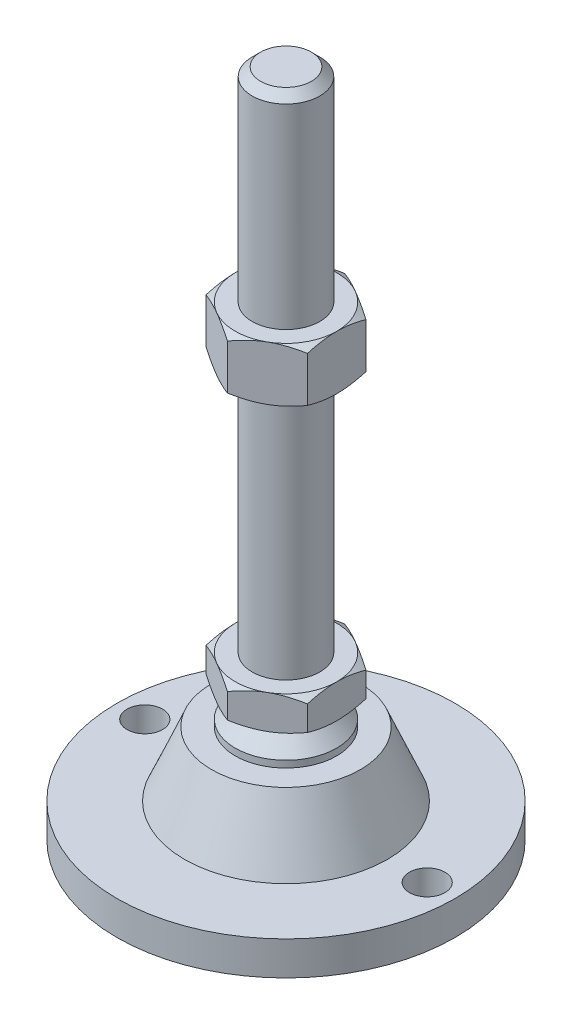
from build123d import *

# Parameters (mm, degrees)
EXTRUDE_1_DEPTH     = 10
EXTRUDE_2_DEPTH     = 16
SKETCH_5_R          = 5.25
CUT_EXTRUDE_1_DEPTH = 11


with BuildPart() as part:
    # Эскиз1 → Повернуть1 (revolve)
    with BuildSketch(Plane.XY, mode=Mode.PRIVATE) as revolve_1_sk:
        Polygon((0, 0), (-50, 0), (-50, 10), (-30, 10), (-22, 29), (-15, 29), (-15, 31), (-10, 36), (-10, 38), (-10, 48), (-10, 195.5), (-7.5, 198), (0, 198), align=None)
    revolve(revolve_1_sk.sketch.rotate(Axis((0, 0, 0), (0, 1, 0)), 180), axis=Axis((0, 0, 0), (0, 1, 0)))  # turned: the seam where the file's is

    # Эскиз2 → Бобышка-Вытянуть1 (add)
    with BuildSketch(Plane(origin=(0, 38, 0), x_dir=(1, 0, 0), z_dir=(0, 1, 0))):
        Polygon((0, 17.320508076), (-15, 8.660254038), (-15, -8.660254038), (0, -17.320508076), (15, -8.660254038), (15, 8.660254038), align=None)
    extrude(amount=EXTRUDE_1_DEPTH)

    # Эскиз3 → Бобышка-Вытянуть2 (add)
    with BuildSketch(Plane(origin=(0, 121.75, 0), x_dir=(1, 0, 0), z_dir=(0, 1, 0))):
        Polygon((15, 8.660254038), (0, 17.320508076), (-15, 8.660254038), (-15, -8.660254038), (0, -17.320508076), (15, -8.660254038), align=None)
    extrude(amount=EXTRUDE_2_DEPTH)

    # Эскиз4 → Вырез-Повернуть2 (revolve, cut)
    with BuildSketch(Plane.XY, mode=Mode.PRIVATE) as cut_revolve_2_sk:
        Polygon((-28.856406461, 137.75), (-15, 137.75), (-28.856406461, 129.75), align=None)
        Polygon((-28.856406461, 121.75), (-28.856406461, 129.75), (-15, 121.75), align=None)
        Polygon((-23.660254038, 48), (-23.660254038, 43), (-15, 48), align=None)
        Polygon((-23.660254038, 43), (-23.660254038, 38), (-15, 38), align=None)
    revolve(cut_revolve_2_sk.sketch.rotate(Axis((0, 198, 0), (0, -1, 0)), 180), axis=Axis((0, 198, 0), (0, -1, 0)), mode=Mode.SUBTRACT)  # turned: the seam where the file's is

    # Эскиз5 → Вырез-Вытянуть1 (cut, through all)
    with BuildSketch(Plane(origin=(0, 10, 0), x_dir=(1, 0, 0), z_dir=(0, 1, 0))):
        with Locations(Location((-41.75, 0, 0), (0, 0, 180))):  # turned: the seam where the file's is
            Circle(SKETCH_5_R)
        with Locations(Location((41.75, 0, 0), (0, 0, 180))):  # turned: the seam where the file's is
            Circle(SKETCH_5_R)
    extrude(amount=-CUT_EXTRUDE_1_DEPTH, mode=Mode.SUBTRACT)


solid = part.part
